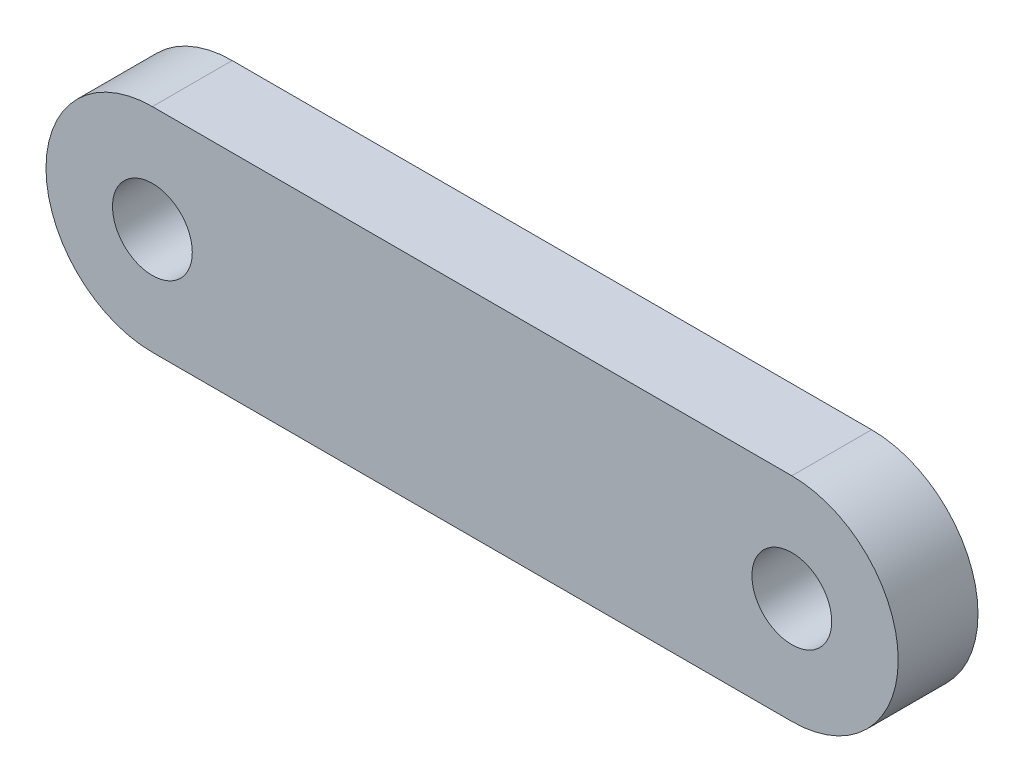
from build123d import *

# Parameters (mm, degrees)
SKETCH1_R           = 0.75
BOSS_EXTRUDE1_DEPTH = 0.75


with BuildPart() as part:
    # Sketch1 → Boss-Extrude1 (new body, symmetric)
    with BuildSketch(Plane.XY):
        with BuildLine():
            Line((0, 2), (12.02, 2))
            ThreePointArc((12.02, 2), (14.02, 0), (12.02, -2))
            Line((12.02, -2), (0, -2))
            ThreePointArc((0, -2), (-2, 0), (0, 2))
        make_face()
        Circle(SKETCH1_R, mode=Mode.SUBTRACT)
        with Locations((12.02, 0)):
            Circle(SKETCH1_R, mode=Mode.SUBTRACT)
    extrude(amount=BOSS_EXTRUDE1_DEPTH, both=True)


solid = part.part
